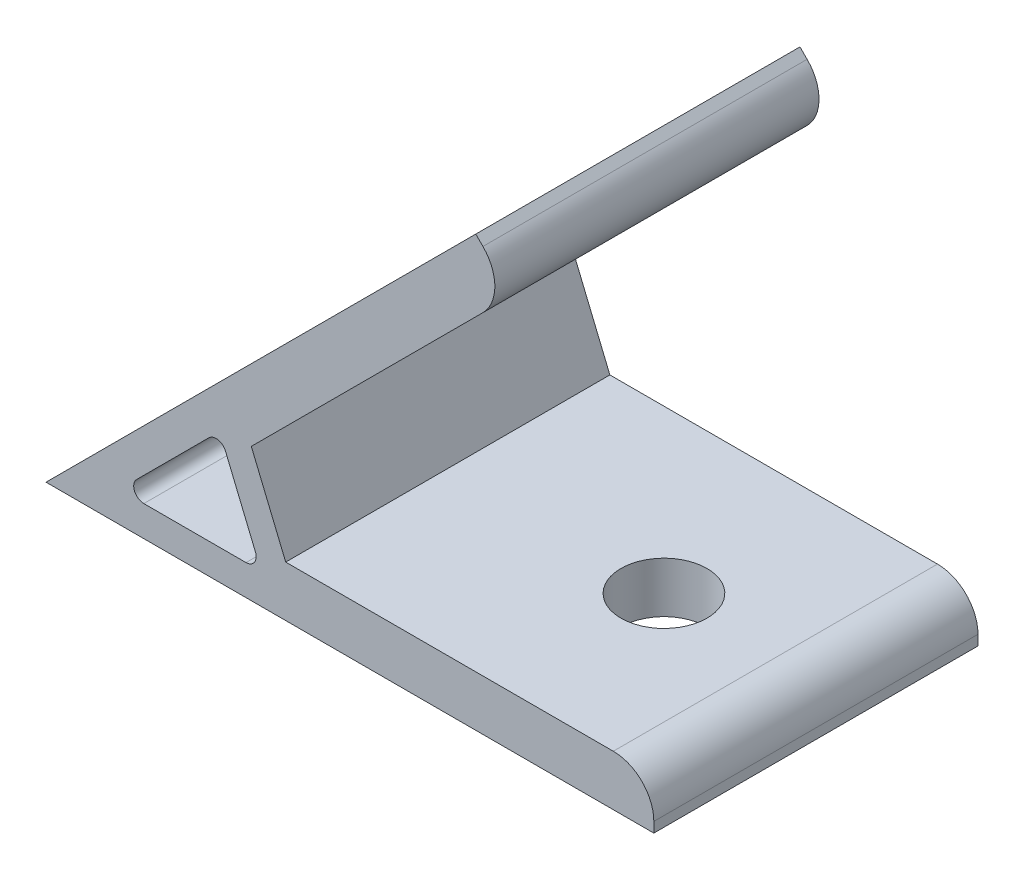
from build123d import *

# Parameters (mm, degrees)
EXTRUDE_1_DEPTH     = 16
SKETCH_2_R          = 4.25
CUT_EXTRUDE_1_DEPTH = 5
SKETCH_3_R          = 4.25
CUT_EXTRUDE_2_DEPTH = 5
FILLET_1_R          = 4
FILLET_2_R          = 1


with BuildPart() as part:
    # Эскиз1 → Бобышка-Вытянуть1 (new body, symmetric)
    with BuildSketch(Plane.XY):
        Polygon((0, 0), (42.426406871, 42.426406871), (45.961940777, 38.890872965), (20.266663343, 13.195595531), (23.661390163, 5), (60, 5), (60, 0), align=None)
        Polygon((17.142135624, 12.899494937), (21.242640687, 3), (7.242640687, 3), align=None, mode=Mode.SUBTRACT)
    extrude(amount=EXTRUDE_1_DEPTH, both=True)

    # Эскиз2 → Вырез-Вытянуть1 (cut)
    with BuildSketch(Plane(origin=(0, 0, 0), x_dir=(0, 0, 1), z_dir=(-0.707106781, 0.707106781, 0))):
        with Locations(Location((0, 45, 0), (0, 0, 270))):  # turned: the seam where the file's is
            Circle(SKETCH_2_R)
    extrude(amount=-CUT_EXTRUDE_1_DEPTH, mode=Mode.SUBTRACT)

    # Эскиз3 → Вырез-Вытянуть2 (cut)
    with BuildSketch(Plane.XZ):
        with Locations(Location((45, 0, 0), (0, 0, 270))):  # turned: the seam where the file's is
            Circle(SKETCH_3_R)
    extrude(amount=-CUT_EXTRUDE_2_DEPTH, mode=Mode.SUBTRACT)

    # Скругление1
    fillet_1_edges = [part.edges().sort_by_distance(p)[0] for p in [
        (45.961940777, 38.890872965, 0),
        (60, 5, 0),
    ]]
    fillet(fillet_1_edges, radius=FILLET_1_R)

    # Скругление2
    fillet_2_edges = [part.edges().sort_by_distance(p)[0] for p in [
        (17.142135624, 12.899494937, 0),
        (7.242640687, 3, 0),
        (21.242640687, 3, 0),
    ]]
    fillet(fillet_2_edges, radius=FILLET_2_R)


solid = part.part
